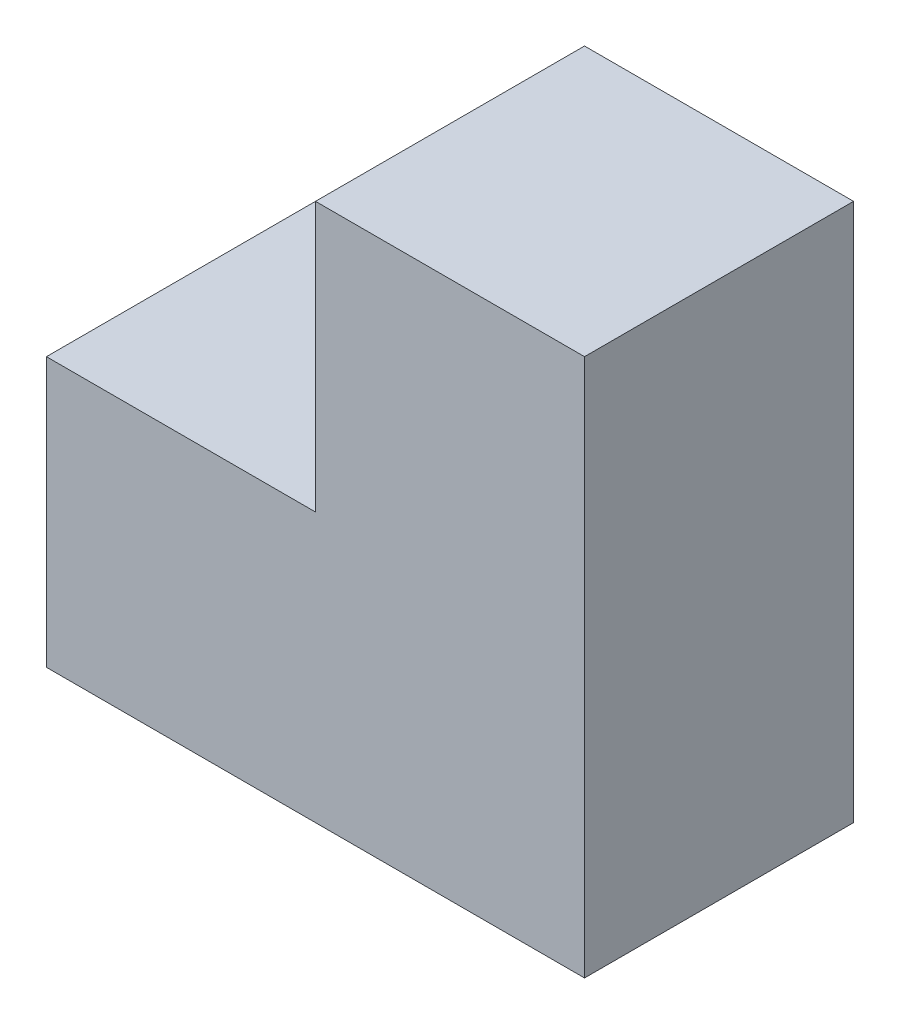
from build123d import *

# Parameters (mm, degrees)
BOSS_EXTRUDE1_DEPTH = 30


with BuildPart() as part:
    # Sketch1 → Boss-Extrude1 (new body)
    with BuildSketch(Plane.XY):
        Polygon((0, 0), (60, 0), (60, 60), (30, 60), (30, 30), (0, 30), align=None)
    extrude(amount=BOSS_EXTRUDE1_DEPTH)


solid = part.part
